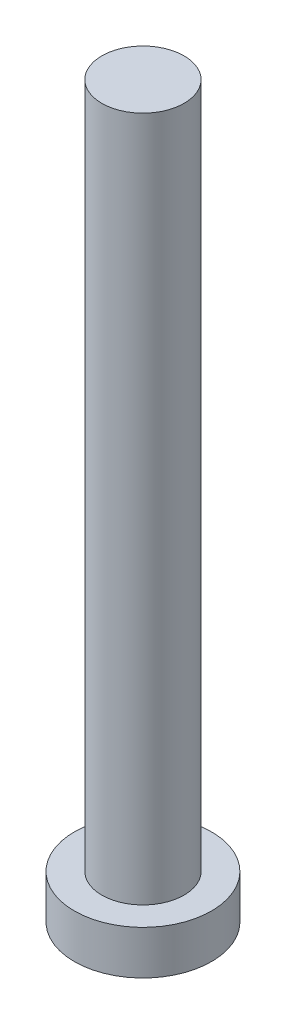
from build123d import *

# Parameters (mm, degrees)
SKETCH_1_R          = 2.5
EXTRUDE_1_DEPTH     = 1.6
SKETCH_2_R          = 1.5
EXTRUDE_2_DEPTH     = 25
CUT_EXTRUDE_1_DEPTH = 1


with BuildPart() as part:
    # 草图1 → 凸台-拉伸1 (new body)
    with BuildSketch(Plane(origin=(0, 0, 0), x_dir=(1, 0, 0), z_dir=(0, 1, 0))):
        Circle(SKETCH_1_R)
    extrude(amount=EXTRUDE_1_DEPTH)

    # 草图2 → 凸台-拉伸2 (add)
    with BuildSketch(Plane(origin=(0, 1.6, 0), x_dir=(1, 0, 0), z_dir=(0, 1, 0))):
        Circle(SKETCH_2_R)
    extrude(amount=EXTRUDE_2_DEPTH)

    # 草图3 → 切除-拉伸1 (cut)
    with BuildSketch(Plane.XZ):
        with BuildLine():
            Line((-0.5, 1), (-0.5, 1.75))
            Line((-0.5, 1.75), (0.5, 1.75))
            Line((0.5, 1.75), (0.5, 1))
            ThreePointArc((0.5, 1), (0.646446609, 0.646446609), (1, 0.5))
            Line((1, 0.5), (1.75, 0.5))
            Line((1.75, 0.5), (1.75, -0.5))
            Line((1.75, -0.5), (1, -0.5))
            ThreePointArc((1, -0.5), (0.646446609, -0.646446609), (0.5, -1))
            Line((0.5, -1), (0.5, -1.75))
            Line((0.5, -1.75), (-0.5, -1.75))
            Line((-0.5, -1.75), (-0.5, -1))
            ThreePointArc((-0.5, -1), (-0.646446609, -0.646446609), (-1, -0.5))
            Line((-1, -0.5), (-1.75, -0.5))
            Line((-1.75, -0.5), (-1.75, 0.5))
            Line((-1.75, 0.5), (-1, 0.5))
            ThreePointArc((-1, 0.5), (-0.646446609, 0.646446609), (-0.5, 1))
        make_face()
    extrude(amount=-CUT_EXTRUDE_1_DEPTH, mode=Mode.SUBTRACT)


solid = part.part
